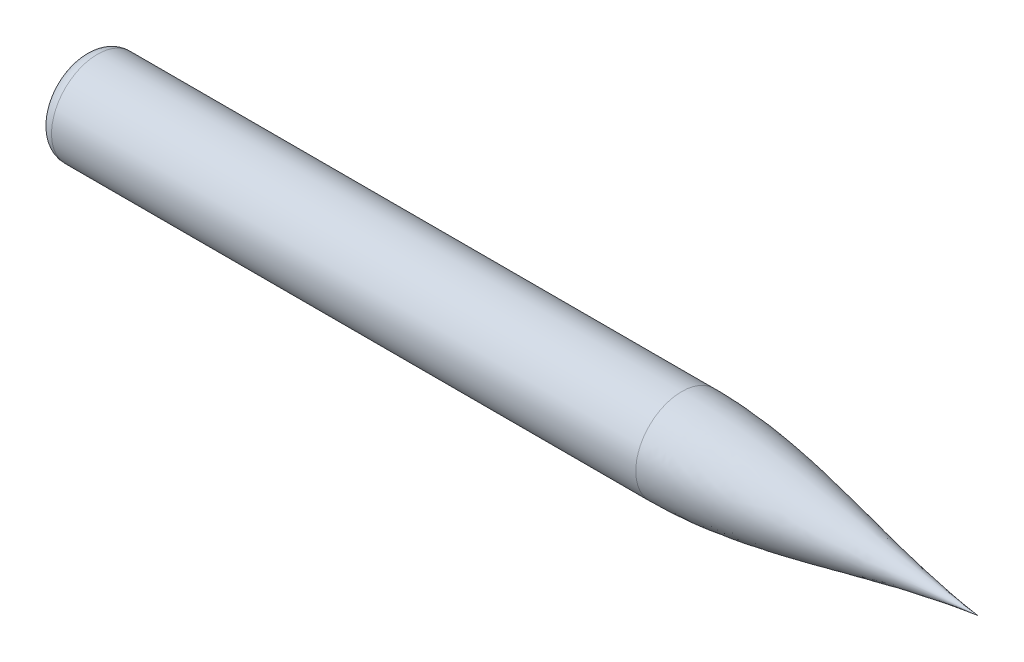
from build123d import *


with BuildPart() as part:
    # Sketch8 → Revolve5 (revolve)
    with BuildSketch(Plane.XY):
        with BuildLine():
            Line((-16019.160674831, 19794.238554782), (-16019.160674831, 19912.92470728))
            ThreePointArc((-16019.160674831, 19912.92470728), (-16004.51601389, 19948.280046339), (-15969.160674831, 19962.92470728))
            Line((-15969.160674831, 19962.92470728), (-15187.150890895, 19962.92470728))
            Line((-15187.150890895, 19962.92470728), (-13822.334310087, 19962.92470728))
            add(Edge.make_bspline(
                [(-13822.334310087, 19962.92470728), (-13455.04791629, 19963.773071151), (-13107.225974635, 19836.105112744), (-12733.46098639, 19794.238554782)],
                knots=[0, 0, 0, 0, 1, 1, 1, 1], degree=3))
            Line((-12733.46098639, 19794.238554782), (-16019.160674831, 19794.238554782))
        make_face()
    revolve(axis=Axis((-12733.46098639, 19794.238554782, 0), (-1, 0, 0)))


solid = part.part
